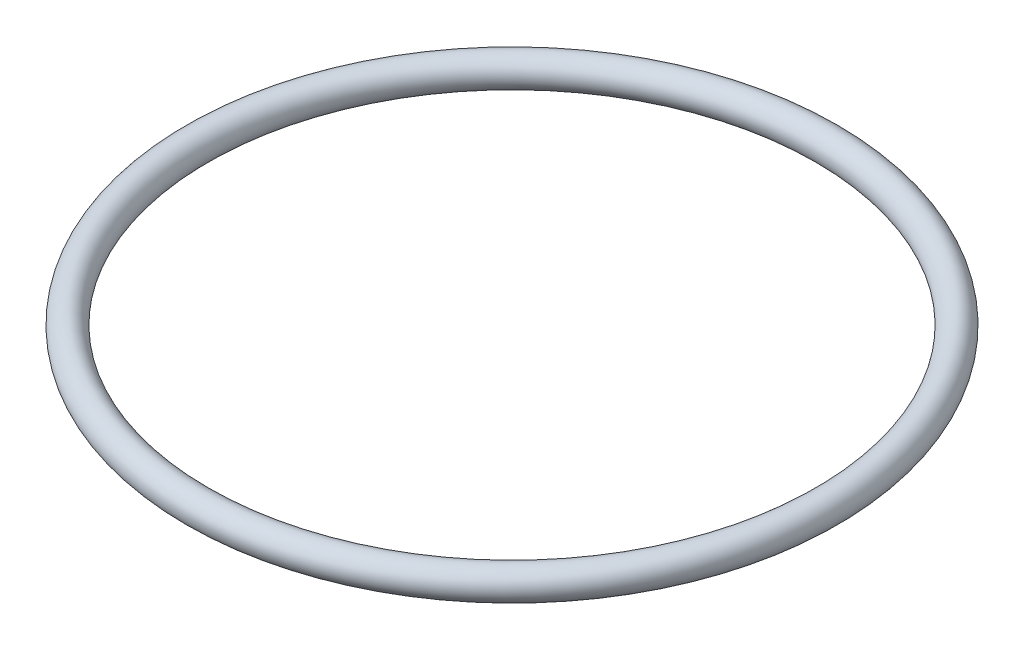
from build123d import *

# Parameters (mm, degrees)
SCHIZZO1_R = 1


with BuildPart() as part:
    # Schizzo1 → Rivoluzione1 (revolve)
    with BuildSketch(Plane.XY):
        with Locations((19.648033701, 0)):
            Circle(SCHIZZO1_R)
    revolve(axis=Axis((-1.051966299, 0, 0), (0, 1, 0)))


solid = part.part
